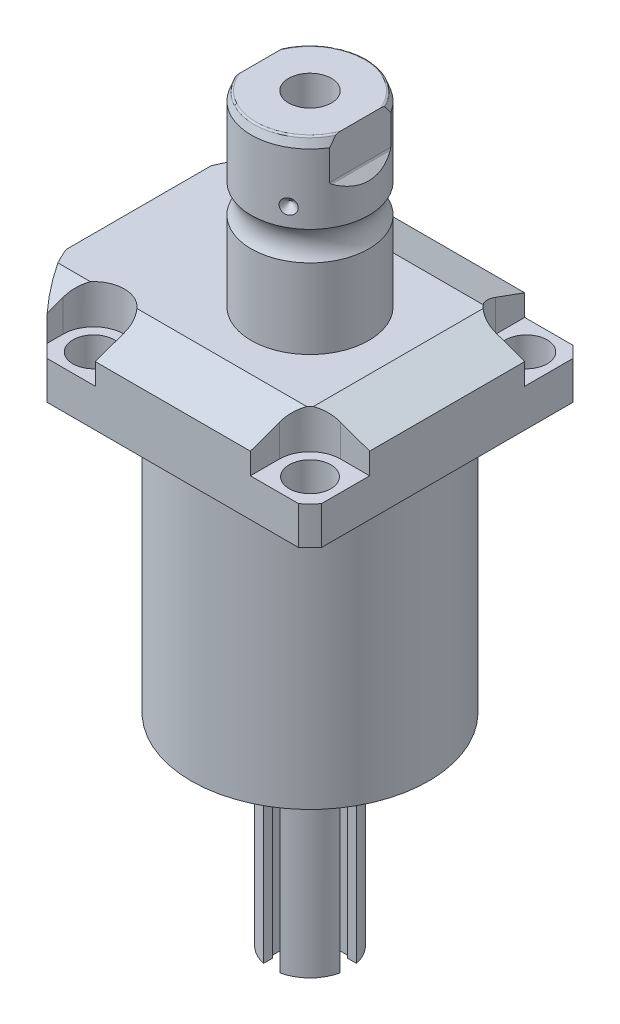
from build123d import *

# Parameters (mm, degrees)
SKETCH1_W                   = 88.9
SKETCH1_H                   = 100
EXTRUDE1_DEPTH              = 113.919
SKETCH2_OUTSIDE_W           = 137.146
SKETCH2_OUTSIDE_H           = 126.046
SKETCH2_OUTSIDE_R           = 60.325
CUT_EXTRUDE1_DEPTH          = 114.919
SKETCH3_W                   = 38.1002
SKETCH3_H                   = 88.9
FILLET1_R                   = 0.381
CUT_EXTRUDE2_DEPTH          = 12.7
CUT_EXTRUDE9_START          = -56.55
CUT_EXTRUDE9_DEPTH          = 102
CUT_EXTRUDE7_DEPTH          = 45.45
CUT_EXTRUDE7_DEPTH_BACK     = 45.45
SKETCH10_R                  = 1.1811
SKETCH11_R                  = 1.1811
LPATTERN1_COUNT             = 2
LPATTERN1_PITCH             = 25.9588
CUT_EXTRUDE8_DEPTH          = 53.34
SKETCH17_W                  = 6.7435
SKETCH17_H                  = 12.319
HOLE1_AT_2_COUNT            = 2
HOLE1_AT_2_PITCH            = 70.104
HOLE1_AT_3_COUNT            = 2
HOLE1_AT_3_PITCH            = 99.142027577
HOLE1_AT_4_COUNT            = 2
HOLE1_AT_4_PITCH            = 70.104
CHAMFER1_SIZE               = 0.635
FILLET2_R                   = 0.635
CIRPATTERN1_COUNT           = 3
SKETCH24_R                  = 1.727203454
SKETCH24_R_2                = 1.727203455
CUT_EXTRUDE10_DEPTH         = 2.540005
SKETCH25_R                  = 2.70510541
EXTRUDE2_DEPTH              = 2.946405893
CUT_EXTRUDE11_DEPTH         = 2.032004064
CUT_EXTRUDE12_DEPTH         = 6.477012954
SKETCH28_W                  = 6.98501397
SKETCH28_H                  = 54.864109728
CUT_EXTRUDE13_DEPTH         = 3.302006604
CIRPATTERN2_COUNT           = 2
CIRPATTERN2_ANGLE           = 90
CIRPATTERN2_COPY_1_DEPTH    = 6.477012954
CIRPATTERN2_COPY_2_SKETCH_W = 6.98501397
CIRPATTERN2_COPY_2_SKETCH_H = 54.864109728
CIRPATTERN2_COPY_2_DEPTH    = 3.302006604


with BuildPart() as part:
    # Sketch1 → Extrude1 (new body)
    with BuildSketch(Plane.ZX):
        with Locations((0, -5.55)):
            Rectangle(SKETCH1_W, SKETCH1_H)
    extrude(amount=EXTRUDE1_DEPTH)

    # Sketch2 outside → Cut-Extrude1 (cut, through all)
    with BuildSketch(Plane.XZ):
        with Locations((-5.55, 0)):
            Rectangle(SKETCH2_OUTSIDE_W, SKETCH2_OUTSIDE_H)
        Circle(SKETCH2_OUTSIDE_R, mode=Mode.SUBTRACT)
    extrude(amount=-CUT_EXTRUDE1_DEPTH, mode=Mode.SUBTRACT)

    # Sketch3 → Cut-Revolve1 (revolve, cut)
    with BuildSketch(Plane(origin=(0, 0, 0), x_dir=(0, 0, 1), z_dir=(1, 0, 0))):
        with Locations((57.5436, -44.45)):
            Rectangle(SKETCH3_W, SKETCH3_H)
    revolve(axis=Axis((0, 93.345, 0), (0, -1, 0)), mode=Mode.SUBTRACT)

    # Fillet1
    fillet1_edges = [part.edges().sort_by_distance(p)[0] for p in [
        (0, 88.9, -38.4935),
    ]]
    fillet(fillet1_edges, radius=FILLET1_R)

    # Sketch4 → Cut-Extrude2 (cut)
    with BuildSketch(Plane(origin=(0, 113.919, 0), x_dir=(-1, 0, 0), z_dir=(0, 1, 0))):
        with BuildLine():
            Line((-25.121, -44.45), (-25.121, -35.052))
            ThreePointArc((-25.121, -35.052), (-28.029722556, -28.029722556), (-35.052, -25.121))
            Line((-35.052, -25.121), (-44.45, -25.121))
            Line((-44.45, -25.121), (-44.45, -44.45))
            Line((-44.45, -44.45), (-25.121, -44.45))
        make_face()
        with BuildLine():
            Line((44.983, -44.45), (25.121, -44.45))
            Line((25.121, -44.45), (25.121, -35.052))
            ThreePointArc((25.121, -35.052), (35.052, -25.121), (44.983, -35.052))
            Line((44.983, -35.052), (44.983, -44.45))
        make_face()
        with BuildLine():
            Line((25.121, 44.45), (25.121, 35.052))
            ThreePointArc((25.121, 35.052), (35.052, 25.121), (44.983, 35.052))
            Line((44.983, 35.052), (44.983, 44.45))
            Line((44.983, 44.45), (25.121, 44.45))
        make_face()
        with BuildLine():
            Line((-35.052, 25.121), (-44.45, 25.121))
            Line((-44.45, 25.121), (-44.45, 44.45))
            Line((-44.45, 44.45), (-25.121, 44.45))
            Line((-25.121, 44.45), (-25.121, 35.052))
            ThreePointArc((-25.121, 35.052), (-28.029722556, 28.029722556), (-35.052, 25.121))
        make_face()
    extrude(amount=-CUT_EXTRUDE2_DEPTH, mode=Mode.SUBTRACT)

    # Sketch5 → Cut-Extrude9 (cut)
    with BuildSketch(Plane(origin=(0, 0, 0), x_dir=(0, 0, -1), z_dir=(1, 0, 0)).offset(CUT_EXTRUDE9_START)):
        Polygon((-28.575, 113.919), (-44.45, 108.140972531), (-44.45, 113.919), align=None)
    cut_extrude9 = extrude(amount=CUT_EXTRUDE9_DEPTH, mode=Mode.SUBTRACT)

    # Mirror1: Cut-Extrude9 across plane
    add(cut_extrude9.mirror(Plane.XY), mode=Mode.SUBTRACT)

    # Sketch9 → Cut-Extrude7 (cut, two sides)
    with BuildSketch(Plane.XY) as cut_extrude7_sk:
        Polygon((28.575, 113.919), (44.45, 108.140972531), (44.45, 113.919), align=None)
    extrude(amount=CUT_EXTRUDE7_DEPTH, mode=Mode.SUBTRACT)
    extrude(cut_extrude7_sk.sketch, amount=-CUT_EXTRUDE7_DEPTH_BACK, mode=Mode.SUBTRACT)

    # Sketch20 → Cut-Revolve4 (revolve, cut)
    with BuildSketch(Plane(origin=(-41.402, 88.9, -18.1102), x_dir=(0, 1, 0), z_dir=(1, 0, 0)), mode=Mode.PRIVATE) as cut_revolve4_sk:
        Polygon((0, 41.9225), (1.4478, 41.9225), (1.4478, 39.4714), (2.4638, 39.4714), (2.4638, 37.4648), (13.4366, 37.4648), (13.4366, 36.2202), (0, 36.2202), align=None)
    cut_revolve4 = revolve(cut_revolve4_sk.sketch.rotate(Axis((-41.402, 81.620304954, 18.11), (0, 1, 0)), 180), axis=Axis((-41.402, 81.620304954, 18.11), (0, 1, 0)), mode=Mode.SUBTRACT)  # turned: the seam where the file's is

    # Mirror10: Cut-Revolve4 across plane
    add(cut_revolve4.mirror(Plane.XY), mode=Mode.SUBTRACT)

    # S2D0007 → Cut-Revolve2 (revolve, cut)
    with BuildSketch(Plane(origin=(-55.5498, 101.9048, 12.9794), x_dir=(0, 1, 0), z_dir=(0, 0, 1)), mode=Mode.PRIVATE) as cut_revolve2_sk:
        Polygon((0.0002, 0.0002), (10.7444, 0.0002), (10.7444, -0.2538), (6.655, -0.2538), (5.9438, -0.965), (5.9438, -14.427), (0.0002, -14.427), align=None)
    cut_revolve2 = revolve(cut_revolve2_sk.sketch.rotate(Axis((-40.6146, 101.905, 12.9794), (-1, 0, 0)), 90), axis=Axis((-40.6146, 101.905, 12.9794), (-1, 0, 0)), mode=Mode.SUBTRACT)  # turned: the seam where the file's is

    # LPattern1: Cut-Revolve2 ×2
    with Locations(*[(0, 0, -i * LPATTERN1_PITCH) for i in range(1, LPATTERN1_COUNT)]):
        add(cut_revolve2, mode=Mode.SUBTRACT)

    # Sketch15 → Revolve3 (revolve)
    with BuildSketch(Plane(origin=(0, 0, 0), x_dir=(0, -1, 0), z_dir=(1, 0, 0)), mode=Mode.PRIVATE) as revolve3_sk:
        with BuildLine():
            Line((-113.919, 0), (-113.919, 19.05))
            Line((-113.919, 19.05), (-139.640705156, 19.05))
            ThreePointArc((-139.640705156, 19.05), (-144.348, 17.5005), (-149.055294844, 19.05))
            Line((-149.055294844, 19.05), (-171.602, 19.05))
            Line((-171.602, 19.05), (-174.523, 17.986842946))
            Line((-174.523, 17.986842946), (-174.523, 0))
            Line((-174.523, 0), (-113.919, 0))
        make_face()
    revolve(revolve3_sk.sketch.rotate(Axis((0, 197.63613, 0), (0, -1, 0)), 180), axis=Axis((0, 197.63613, 0), (0, -1, 0)))  # turned: the seam where the file's is

    # Sketch16 → Cut-Extrude8 (cut, symmetric)
    with BuildSketch(Plane(origin=(0, 0, 0), x_dir=(0, -1, 0), z_dir=(0, 0, 1))):
        with BuildLine():
            Line((-174.523, 19.05), (-158.738869265, 19.05))
            Line((-158.738869265, 19.05), (-161.284184633, 16.504684633))
            ThreePointArc((-161.284184633, 16.504684633), (-161.531395225, 16.339503796), (-161.823, 16.2815))
            Line((-161.823, 16.2815), (-174.523, 16.2815))
            Line((-174.523, 16.2815), (-174.523, 19.05))
        make_face()
        with BuildLine():
            Line((-174.523, -19.05), (-174.523, -16.2815))
            Line((-174.523, -16.2815), (-161.823, -16.2815))
            ThreePointArc((-161.823, -16.2815), (-161.531395225, -16.339503796), (-161.284184633, -16.504684633))
            Line((-161.284184633, -16.504684633), (-158.738869265, -19.05))
            Line((-158.738869265, -19.05), (-174.523, -19.05))
        make_face()
    extrude(amount=CUT_EXTRUDE8_DEPTH, both=True, mode=Mode.SUBTRACT)

    # Sketch17 → Hole1 (revolve, cut)
    with BuildSketch(Plane(origin=(35.052, 101.219, -35.052), x_dir=(0, 0, 1), z_dir=(1, 0, 0))):
        with Locations((3.37175, 6.1595)):
            Rectangle(SKETCH17_W, SKETCH17_H)
    hole1 = revolve(axis=Axis((35.052, -8.781, -35.052), (0, 1, 0)), mode=Mode.SUBTRACT)

    # Hole1 at 2: Hole1 ×2
    with Locations(*[(0, 0, i * HOLE1_AT_2_PITCH) for i in range(1, HOLE1_AT_2_COUNT)]):
        add(hole1, mode=Mode.SUBTRACT)

    # Hole1 at 3: Hole1 ×2
    with Locations(*[Vector(-0.707106781, 0, 0.707106781) * (i * HOLE1_AT_3_PITCH) for i in range(1, HOLE1_AT_3_COUNT)]):
        add(hole1, mode=Mode.SUBTRACT)

    # Hole1 at 4: Hole1 ×2
    with Locations(*[(-i * HOLE1_AT_4_PITCH, 0, 0) for i in range(1, HOLE1_AT_4_COUNT)]):
        add(hole1, mode=Mode.SUBTRACT)

    # Chamfer1
    chamfer1_edges = [part.edges().sort_by_distance(p)[0] for p in [
        (-41.402, 91.3638, 19.3546),
        (-41.402, 91.3638, -19.3546),
    ]]
    chamfer(chamfer1_edges, length=CHAMFER1_SIZE)

    # Sketch21 → Cut-Revolve5 (revolve, cut)
    with BuildSketch(Plane.XY, mode=Mode.PRIVATE) as cut_revolve5_sk:
        Polygon((0, 144.956512296), (6.9342, 149.123), (6.9342, 174.523), (0, 174.523), align=None)
    revolve(cut_revolve5_sk.sketch.rotate(Axis((0, 0, 0), (0, 1, 0)), 270), axis=Axis((0, 0, 0), (0, 1, 0)), mode=Mode.SUBTRACT)  # turned: the seam where the file's is

    # Fillet2
    fillet2_edges = [part.edges().sort_by_distance(p)[0] for p in [
        (0, 174.523, -17.986842946),
        (0, 174.523, 17.986842946),
    ]]
    fillet(fillet2_edges, radius=FILLET2_R)

    # Sketch22 → Cut-Revolve6 (revolve, cut)
    with BuildSketch(Plane.XY, mode=Mode.PRIVATE) as cut_revolve6_sk:
        Polygon((-19.05, 157.429), (-16.637, 155.016), (-19.05, 155.016), align=None)
    cut_revolve6 = revolve(cut_revolve6_sk.sketch.rotate(Axis((-37.997376206, 155.016, 0), (1, 0, 0)), 90), axis=Axis((-37.997376206, 155.016, 0), (1, 0, 0)), mode=Mode.SUBTRACT)  # turned: the seam where the file's is

    # CirPattern1: Cut-Revolve6 ×3 about axis
    cirpattern1_axis = Axis((0, 197.63613, 0), (0, 1, 0))
    for i in range(1, CIRPATTERN1_COUNT):
        add(cut_revolve6.rotate(cirpattern1_axis, i * 360 / CIRPATTERN1_COUNT), mode=Mode.SUBTRACT)

    # Sketch23 → Revolve5 (revolve)
    with BuildSketch(Plane.XY, mode=Mode.PRIVATE) as revolve5_sk:
        Polygon((0, 0), (-22.22504445, 0), (-22.22504445, -2.54000508), (-12.7000254, -2.54000508), (-12.7000254, -65.532131064), (0, -65.532131064), align=None)
    revolve(revolve5_sk.sketch.rotate(Axis((0, -970.243484238, 0), (0, 1, 0)), 90), axis=Axis((0, -970.243484238, 0), (0, 1, 0)))  # turned: the seam where the file's is

    # Sketch24 → Cut-Extrude10 (cut)
    with BuildSketch(Plane.XZ.offset(2.54000508)):
        with Locations((19.431038862, 0)):
            Circle(SKETCH24_R)
        with Locations((16.827773276, 9.715519431)):
            Circle(SKETCH24_R_2)
        with Locations((9.715519431, 16.827773276)):
            Circle(SKETCH24_R_2)
        with Locations((0, 19.431038862)):
            Circle(SKETCH24_R_2)
        with Locations(Location((-9.715519431, 16.827773276, 0), (0, 0, 90))):  # turned: the seam where the file's is
            Circle(SKETCH24_R_2)
        with Locations(Location((-16.827773276, 9.715519431, 0), (0, 0, 90))):  # turned: the seam where the file's is
            Circle(SKETCH24_R_2)
        with Locations(Location((-19.431038862, 0, 0), (0, 0, 90))):  # turned: the seam where the file's is
            Circle(SKETCH24_R)
        with Locations(Location((16.827773276, -9.715519431, 0), (0, 0, 90))):  # turned: the seam where the file's is
            Circle(SKETCH24_R_2)
        with Locations(Location((9.715519431, -16.827773276, 0), (0, 0, 90))):  # turned: the seam where the file's is
            Circle(SKETCH24_R_2)
        with Locations(Location((0, -19.431038862, 0), (0, 0, 90))):  # turned: the seam where the file's is
            Circle(SKETCH24_R_2)
        with Locations((-9.715519431, -16.827773276)):
            Circle(SKETCH24_R_2)
        with Locations((-16.827773276, -9.715519431)):
            Circle(SKETCH24_R_2)
    extrude(amount=-CUT_EXTRUDE10_DEPTH, mode=Mode.SUBTRACT)

    # Sketch25 → Extrude2 (add)
    with BuildSketch(Plane.XZ.offset(2.54000508)):
        with Locations(Location((19.431038862, 0, 0), (0, 0, 180))):  # turned: the seam where the file's is
            Circle(SKETCH25_R)
        with Locations(Location((-9.715519431, 16.827773276, 0), (0, 0, 180))):  # turned: the seam where the file's is
            Circle(SKETCH25_R)
        with Locations(Location((-9.715519431, -16.827773276, 0), (0, 0, 180))):  # turned: the seam where the file's is
            Circle(SKETCH25_R)
    extrude(amount=EXTRUDE2_DEPTH)

    # Sketch26 → Cut-Extrude11 (cut)
    with BuildSketch(Plane.XZ.offset(5.486410973)):
        Polygon((-9.015346284, -18.089950323), (-8.272355471, -16.852494067), (-8.972528618, -15.590317021), (-10.415692578, -15.56559623), (-11.158683391, -16.803052486), (-10.458510244, -18.065229532), align=None)
        Polygon((19.997647268, -1.327512052), (20.864002226, -0.173058753), (20.29739382, 1.154453299), (18.864430456, 1.327512052), (17.998075498, 0.173058753), (18.564683904, -1.154453299), align=None)
        Polygon((-9.039164395, 15.552674379), (-8.273073875, 16.775964471), (-8.949428911, 18.051063368), (-10.391874467, 18.102872174), (-11.157964987, 16.879582082), (-10.481609951, 15.604483185), align=None)
    extrude(amount=-CUT_EXTRUDE11_DEPTH, mode=Mode.SUBTRACT)

    # Sketch27 → Cut-Extrude12 (cut)
    with BuildSketch(Plane(origin=(0, -34.036068072, 12.7000254), x_dir=(-1, 0, 0), z_dir=(0, 0, 1))):
        with BuildLine():
            Line((-2.641605283, 31.496062992), (-2.641605283, -21.083429092))
            ThreePointArc((-2.641605283, -21.083429092), (0, -26.860546736), (2.641605283, -21.083429092))
            Line((2.641605283, -21.083429092), (2.641605283, 31.496062992))
            Line((2.641605283, 31.496062992), (-2.641605283, 31.496062992))
        make_face()
    cut_extrude12 = extrude(amount=-CUT_EXTRUDE12_DEPTH, mode=Mode.SUBTRACT)

    # Sketch28 → Cut-Extrude13 (cut)
    with BuildSketch(Plane.XY.offset(6.223012446)):
        with Locations((0, -38.1000762)):
            Rectangle(SKETCH28_W, SKETCH28_H)
    cut_extrude13 = extrude(amount=CUT_EXTRUDE13_DEPTH, mode=Mode.SUBTRACT)

    # Mirror11: Cut-Extrude12, Cut-Extrude13 across plane
    add(cut_extrude12.mirror(Plane.XY), mode=Mode.SUBTRACT)
    add(cut_extrude13.mirror(Plane.XY), mode=Mode.SUBTRACT)

    # CirPattern2: Cut-Extrude12, Cut-Extrude13 ×2 about axis
    cirpattern2_axis = Axis((0, 0, 0), (0, -1, 0))
    add([cut_extrude12.rotate(cirpattern2_axis, i * CIRPATTERN2_ANGLE / (CIRPATTERN2_COUNT - 1)) for i in range(1, CIRPATTERN2_COUNT)], mode=Mode.SUBTRACT)
    add([cut_extrude13.rotate(cirpattern2_axis, i * CIRPATTERN2_ANGLE / (CIRPATTERN2_COUNT - 1)) for i in range(1, CIRPATTERN2_COUNT)], mode=Mode.SUBTRACT)

    # CirPattern2 copy 1 sketch → CirPattern2 copy 1 (cut)
    with BuildSketch(Plane(origin=(12.7000254, -34.036068072, 0), x_dir=(0, 0, -1), z_dir=(1, 0, 0))):
        with BuildLine():
            Line((-2.641605283, -31.496062992), (-2.641605283, 21.083429092))
            ThreePointArc((-2.641605283, 21.083429092), (0, 26.860546736), (2.641605283, 21.083429092))
            Line((2.641605283, 21.083429092), (2.641605283, -31.496062992))
            Line((2.641605283, -31.496062992), (-2.641605283, -31.496062992))
        make_face()
    extrude(amount=-CIRPATTERN2_COPY_1_DEPTH, mode=Mode.SUBTRACT)

    # CirPattern2 copy 2 sketch → CirPattern2 copy 2 (cut)
    with BuildSketch(Plane(origin=(6.223012446, 0, 0), x_dir=(0, 0, 1), z_dir=(1, 0, 0))):
        with Locations((0, 38.1000762)):
            Rectangle(CIRPATTERN2_COPY_2_SKETCH_W, CIRPATTERN2_COPY_2_SKETCH_H)
    extrude(amount=CIRPATTERN2_COPY_2_DEPTH, mode=Mode.SUBTRACT)


with BuildPart() as body_2:
    # Sketch10 → Revolve4 (revolve)
    with BuildSketch(Plane(origin=(-41.402, 88.9, -18.1102), x_dir=(0, 1, 0), z_dir=(1, 0, 0))):
        with Locations((0.2667, 4.5214)):
            Circle(SKETCH10_R)
    revolve(axis=Axis((-41.402, 87.86749, -18.11), (0, 1, 0)))


with BuildPart() as body_3:
    # Sketch11 → Revolve2 (revolve)
    with BuildSketch(Plane(origin=(-41.402, 88.9, 18.1102), x_dir=(0, 1, 0), z_dir=(1, 0, 0)), mode=Mode.PRIVATE) as revolve2_sk:
        with Locations((0.2667, 4.521)):
            Circle(SKETCH11_R)
    revolve(revolve2_sk.sketch.rotate(Axis((-41.402, 87.86749, 18.11), (0, 1, 0)), 180), axis=Axis((-41.402, 87.86749, 18.11), (0, 1, 0)))  # turned: the seam where the file's is


solid = Compound([part.part, body_2.part, body_3.part])
